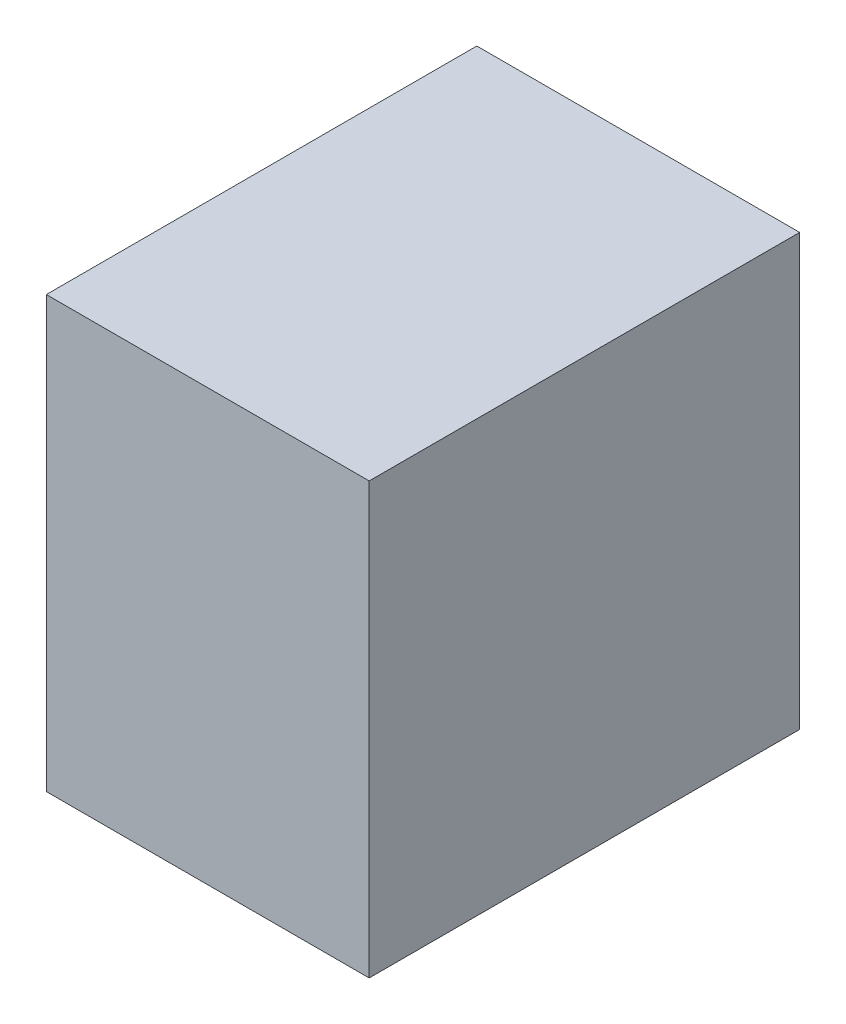
from build123d import *

# Parameters (mm, degrees)
BOSS_EXTRUDE1_DEPTH      = 38.1
BOSS_EXTRUDE1_DEPTH_BACK = 38.1
SKETCH1_W                = 101.6
SKETCH1_H                = 101.6


with BuildPart() as part:
    # Sketch1 → Boss-Extrude1 (new, two sides: drawn at the far end of the back side and taken through both)
    with BuildSketch(Plane(origin=(0, 0, 0), x_dir=(0, 0, -1), z_dir=(1, 0, 0)).offset(-BOSS_EXTRUDE1_DEPTH_BACK)):
        Rectangle(SKETCH1_W, SKETCH1_H)
    extrude(amount=BOSS_EXTRUDE1_DEPTH + BOSS_EXTRUDE1_DEPTH_BACK)


solid = part.part
